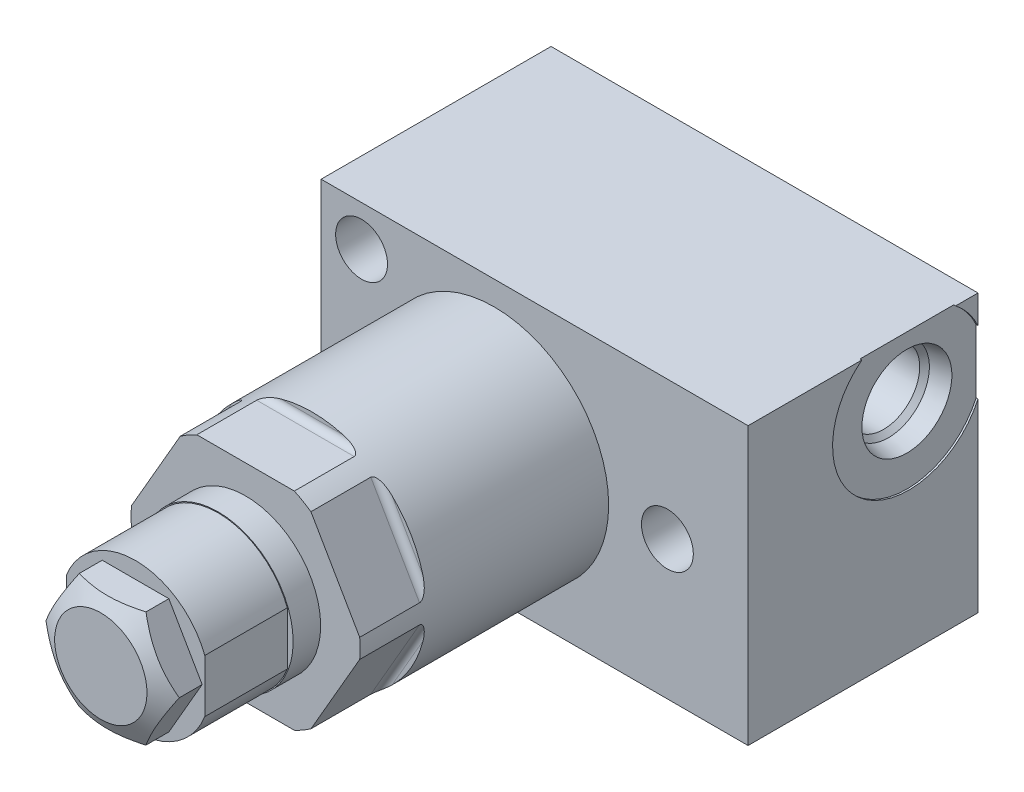
from build123d import *

# Parameters (mm, degrees)
SKETCH1_R           = 15.748
EXTRUDE1_DEPTH      = 55.1434
CUT_EXTRUDE1_DEPTH  = 18.8976
SKETCH11_W          = 15.1384
SKETCH11_H          = 10.3251
CUT_EXTRUDE10_DEPTH = 11.3538
EXTRUDE2_DEPTH      = 4.7752
SKETCH17_W          = 58.7248
SKETCH17_H          = 31.623
EXTRUDE4_DEPTH      = 19.05
SKETCH19_R          = 10.4775
CUT_EXTRUDE12_DEPTH = 0.254
SKETCH22_R          = 1.3335
CIRPATTERN2_COUNT   = 6
SKETCH23_W          = 3.5687
SKETCH23_H          = 31.623
HOLE1_AT_2_COUNT    = 2
HOLE1_AT_2_PITCH    = 44.196072988
HOLE1_AT_3_COUNT    = 2
HOLE1_AT_3_PITCH    = 26.974811959
SKETCH25_W          = 11.3538
SKETCH25_H          = 0.127


with BuildPart() as part:
    # Sketch1 → Extrude1 (new body)
    with BuildSketch(Plane.XY):
        Circle(SKETCH1_R)
    extrude(amount=EXTRUDE1_DEPTH)

    # Sketch2 → Cut-Extrude1 (cut, symmetric)
    with BuildSketch(Plane(origin=(0, 0, 0), x_dir=(0, 0, 1), z_dir=(1, 0, 0))):
        with BuildLine():
            Line((45.9994, 15.748), (45.9994, 15.1638))
            ThreePointArc((45.9994, 15.1638), (46.267221559, 14.517221559), (46.9138, 14.2494))
            Line((46.9138, 14.2494), (55.1434, 14.2494))
            Line((55.1434, 14.2494), (55.1434, 15.748))
            Line((55.1434, 15.748), (45.9994, 15.748))
        make_face()
    cut_extrude1 = extrude(amount=CUT_EXTRUDE1_DEPTH, both=True, mode=Mode.SUBTRACT)

    # Sketch10 → Cut-Revolve1 (revolve, cut)
    with BuildSketch(Plane(origin=(0, 0, 0), x_dir=(0, 0, 1), z_dir=(1, 0, 0)), mode=Mode.PRIVATE) as cut_revolve1_sk:
        Polygon((0, 14.8717), (7.7978, 14.8717), (8.6741, 15.748), (0, 15.748), align=None)
    revolve(cut_revolve1_sk.sketch.rotate(Axis((0, 0, -0.433705), (0, 0, 1)), 90), axis=Axis((0, 0, -0.433705), (0, 0, 1)), mode=Mode.SUBTRACT)  # turned: the seam where the file's is

    # Sketch11 → Revolve1 (revolve)
    with BuildSketch(Plane(origin=(0, 0, 0), x_dir=(0, 0, -1), z_dir=(1, 0, 0)), mode=Mode.PRIVATE) as revolve1_sk:
        with Locations((-62.7126, 5.16255)):
            Rectangle(SKETCH11_W, SKETCH11_H)
    revolve(revolve1_sk.sketch.rotate(Axis((0, 0, 71.154272279), (0, 0, -1)), 90), axis=Axis((0, 0, 71.154272279), (0, 0, -1)))  # turned: the seam where the file's is

    # Sketch14 → Cut-Extrude10 (cut)
    with BuildSketch(Plane.YX.offset(-70.2818)):
        with BuildLine():
            Line((-3.98523086, 9.525), (3.98523086, 9.525))
            ThreePointArc((3.98523086, 9.525), (0, 10.3251), (-3.98523086, 9.525))
        make_face()
        with BuildLine():
            Line((-3.98523086, -9.525), (3.98523086, -9.525))
            ThreePointArc((3.98523086, -9.525), (0, -10.3251), (-3.98523086, -9.525))
        make_face()
    extrude(amount=CUT_EXTRUDE10_DEPTH, mode=Mode.SUBTRACT)

    # Sketch15 → Extrude2 (add)
    with BuildSketch(Plane.XY.offset(70.2818)):
        Polygon((-4.582717762, 7.9375), (4.582717762, 7.9375), (9.165435523, 0), (4.582717762, -7.9375), (-4.582717762, -7.9375), (-9.165435523, 0), align=None)
    extrude(amount=EXTRUDE2_DEPTH)

    # Sketch16 → Cut-Revolve3 (revolve, cut)
    with BuildSketch(Plane(origin=(0, 0, 0), x_dir=(1, 0, 0), z_dir=(0, 1, 0))):
        Polygon((6.35, -75.057), (9.165435523, -73.431507543), (9.165435523, -75.057), align=None)
    revolve(axis=Axis((0, 0, 75.265274623), (0, 0, -1)), mode=Mode.SUBTRACT)

    # Sketch17 → Extrude4 (add, symmetric)
    with BuildSketch(Plane(origin=(0, 0, 0), x_dir=(-1, 0, 0), z_dir=(0, 1, 0))):
        with Locations((-5.5626, 5.1435)):
            Rectangle(SKETCH17_W, SKETCH17_H)
    extrude(amount=EXTRUDE4_DEPTH, both=True)

    # Sketch19 → Cut-Extrude12 (cut)
    with BuildSketch(Plane(origin=(34.925, -19.05, 0), x_dir=(0, 1, 0), z_dir=(1, 0, 0))):
        with Locations((29.845, -1.143)):
            Circle(SKETCH19_R)
    extrude(amount=-CUT_EXTRUDE12_DEPTH, mode=Mode.SUBTRACT)

    # S2D0001 → Cut-Revolve4 (revolve, cut)
    with BuildSketch(Plane(origin=(34.671, 10.795, -1.143), x_dir=(0, -1, 0), z_dir=(0, 0, 1)), mode=Mode.PRIVATE) as cut_revolve4_sk:
        Polygon((0, 0), (6.1849, 0), (5.642306865, -2.5527), (4.9784, -3.216606865), (4.9784, -17.272), (0, -17.272), align=None)
    revolve(cut_revolve4_sk.sketch.rotate(Axis((16.5354, 10.795, -1.143), (1, 0, 0)), 270), axis=Axis((16.5354, 10.795, -1.143), (1, 0, 0)), mode=Mode.SUBTRACT)  # turned: the seam where the file's is

    # Sketch21 → Cut-Revolve5 (revolve, cut)
    with BuildSketch(Plane(origin=(0, 0, -9.329310202), x_dir=(-1, 0, 0), z_dir=(0, 1, 0)), mode=Mode.PRIVATE) as cut_revolve5_sk:
        Polygon((0, -1.338689798), (7.9375, -1.338689798), (7.9375, 1.328310202), (3.4544, 1.328310202), (3.4544, 13.393310202), (0, 15.468923125), align=None)
    revolve(cut_revolve5_sk.sketch.rotate(Axis((0, 0, -11.508380646), (0, 0, 1)), 180), axis=Axis((0, 0, -11.508380646), (0, 0, 1)), mode=Mode.SUBTRACT)  # turned: the seam where the file's is

    # CirPattern2: Cut-Extrude1 ×6 about axis
    cirpattern2_axis = Axis((0, 0, 0), (0, 0, 1))
    for i in range(1, CIRPATTERN2_COUNT):
        add(cut_extrude1.rotate(cirpattern2_axis, i * 360 / CIRPATTERN2_COUNT), mode=Mode.SUBTRACT)

    # Sketch23 → Hole1 (revolve, cut)
    with BuildSketch(Plane(origin=(-18.2626, -13.4874, 20.955), x_dir=(0, -1, 0), z_dir=(1, 0, 0))):
        with Locations((1.78435, 15.8115)):
            Rectangle(SKETCH23_W, SKETCH23_H)
    hole1 = revolve(axis=Axis((-18.2626, -13.4874, -89.045), (0, 0, 1)), mode=Mode.SUBTRACT)

    # Hole1 at 2: Hole1 ×2
    with Locations(*[Vector(0.952297278, 0.30517191, 0) * (i * HOLE1_AT_2_PITCH) for i in range(1, HOLE1_AT_2_COUNT)]):
        add(hole1, mode=Mode.SUBTRACT)

    # Hole1 at 3: Hole1 ×2
    with Locations(*[Vector(0.000941619, 0.999999557, 0) * (i * HOLE1_AT_3_PITCH) for i in range(1, HOLE1_AT_3_COUNT)]):
        add(hole1, mode=Mode.SUBTRACT)

    # Sketch25 → Cut-Revolve6 (revolve, cut)
    with BuildSketch(Plane(origin=(0, 0, 0), x_dir=(0, 0, -1), z_dir=(1, 0, 0)), mode=Mode.PRIVATE) as cut_revolve6_sk:
        with Locations((-64.6049, 10.2616)):
            Rectangle(SKETCH25_W, SKETCH25_H)
    revolve(cut_revolve6_sk.sketch.rotate(Axis((0, 0, -10.668), (0, 0, 1)), 270), axis=Axis((0, 0, -10.668), (0, 0, 1)), mode=Mode.SUBTRACT)  # turned: the seam where the file's is


with BuildPart() as body_2:
    # Sketch22 → Revolve2 (revolve)
    with BuildSketch(Plane(origin=(0, 0, -9.329310202), x_dir=(-1, 0, 0), z_dir=(0, 1, 0))):
        with Locations((-6.604, -0.005189798)):
            Circle(SKETCH22_R)
    revolve(axis=Axis((0, 0, -10.80135), (0, 0, 1)))


solid = Compound([part.part, body_2.part])
